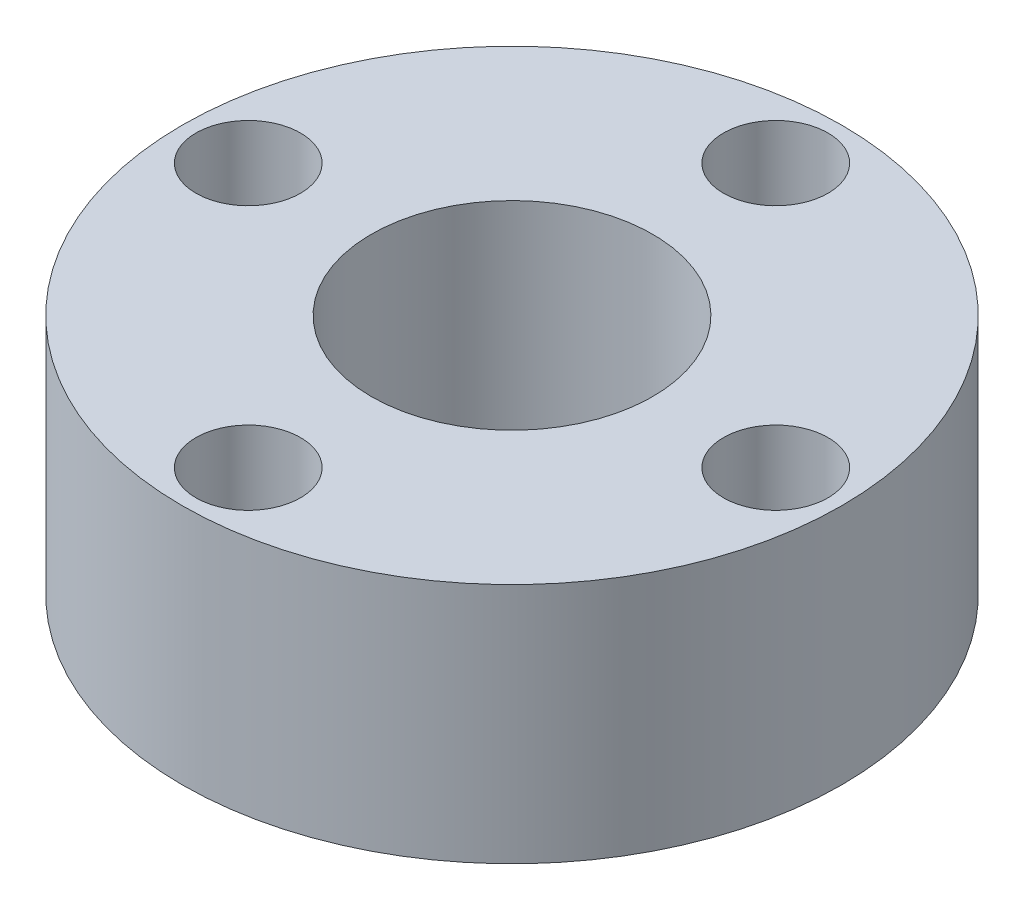
from build123d import *

# Parameters (mm, degrees)
SKETCH1_R           = 9.525
SKETCH1_R_2         = 1.51
SKETCH1_R_3         = 4.064
BOSS_EXTRUDE1_DEPTH = 6.985


with BuildPart() as part:
    # Sketch1 → Boss-Extrude1 (new body)
    with BuildSketch(Plane(origin=(0, 0, 0), x_dir=(1, 0, 0), z_dir=(0, 1, 0))):
        Circle(SKETCH1_R)
        with Locations((0, 7.62)):
            Circle(SKETCH1_R_2, mode=Mode.SUBTRACT)
        with Locations((7.62, 0)):
            Circle(SKETCH1_R_2, mode=Mode.SUBTRACT)
        with Locations((0, -7.62)):
            Circle(SKETCH1_R_2, mode=Mode.SUBTRACT)
        with Locations((-7.62, 0)):
            Circle(SKETCH1_R_2, mode=Mode.SUBTRACT)
        Circle(SKETCH1_R_3, mode=Mode.SUBTRACT)
    extrude(amount=BOSS_EXTRUDE1_DEPTH)


solid = part.part
